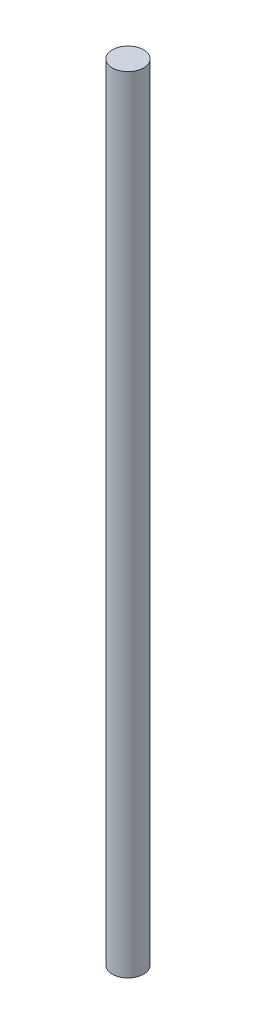
from build123d import *

# Parameters (mm, degrees)
SKETCH1_R           = 2.54
BOSS_EXTRUDE1_DEPTH = 127


with BuildPart() as part:
    # Sketch1 → Boss-Extrude1 (new body)
    with BuildSketch(Plane(origin=(0, 0, 0), x_dir=(1, 0, 0), z_dir=(0, 1, 0))):
        Circle(SKETCH1_R)
    extrude(amount=BOSS_EXTRUDE1_DEPTH)


solid = part.part
